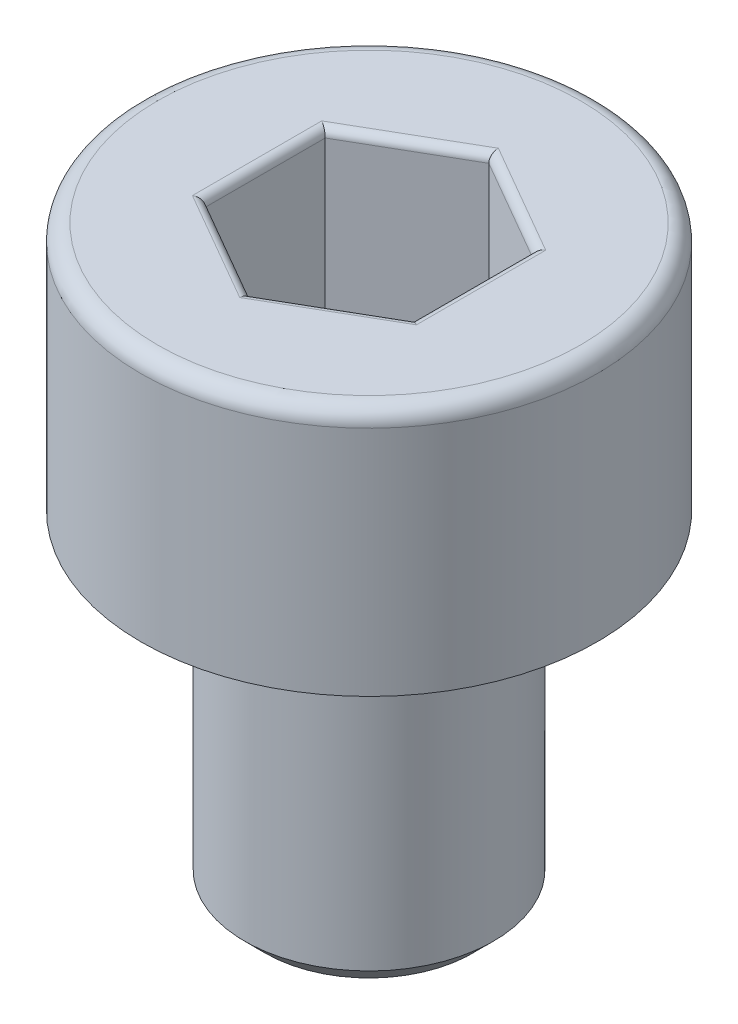
from build123d import *

# Parameters (mm, degrees)
CHAMFER1_SIZE      = 0.25
FILLET1_R          = 0.2
CUT_EXTRUDE1_DEPTH = 2
FILLET2_R          = 0.1


with BuildPart() as part:
    # Sketch1 → Revolve1 (revolve)
    with BuildSketch(Plane.XY):
        Polygon((0, -7), (-1.5, -7), (-1.5, -3), (-2.75, -3), (-2.75, 0), (0, 0), align=None)
    revolve(axis=Axis((0, 0, 0), (0, -1, 0)))

    # Chamfer1
    chamfer1_edges = [part.edges().sort_by_distance(p)[0] for p in [
        (1.5, -3, 0),
        (1.5, -7, 0),
    ]]
    chamfer(chamfer1_edges, length=CHAMFER1_SIZE)

    # Fillet1
    fillet1_edges = [part.edges().sort_by_distance(p)[0] for p in [
        (2.75, 0, 0),
    ]]
    fillet(fillet1_edges, radius=FILLET1_R)

    # Sketch2 → Cut-Extrude1 (cut)
    with BuildSketch(Plane(origin=(0, 0, 0), x_dir=(1, 0, 0), z_dir=(0, 1, 0))):
        Polygon((0, 1.443375673), (-1.25, 0.721687836), (-1.25, -0.721687836), (0, -1.443375673), (1.25, -0.721687836), (1.25, 0.721687836), align=None)
    extrude(amount=-CUT_EXTRUDE1_DEPTH, mode=Mode.SUBTRACT)

    # Fillet2
    fillet2_edges = [part.edges().sort_by_distance(p)[0] for p in [
        (0.625, -2, -1.082531755),
        (1.25, -2, 0),
        (0.625, -2, 1.082531755),
        (-0.625, -2, 1.082531755),
        (-1.25, -2, 0),
        (-0.625, -2, -1.082531755),
        (0.625, 0, -1.082531755),
        (-0.625, 0, -1.082531755),
        (-1.25, 0, 0),
        (-0.625, 0, 1.082531755),
        (0.625, 0, 1.082531755),
        (1.25, 0, 0),
    ]]
    fillet(fillet2_edges, radius=FILLET2_R)


solid = part.part
